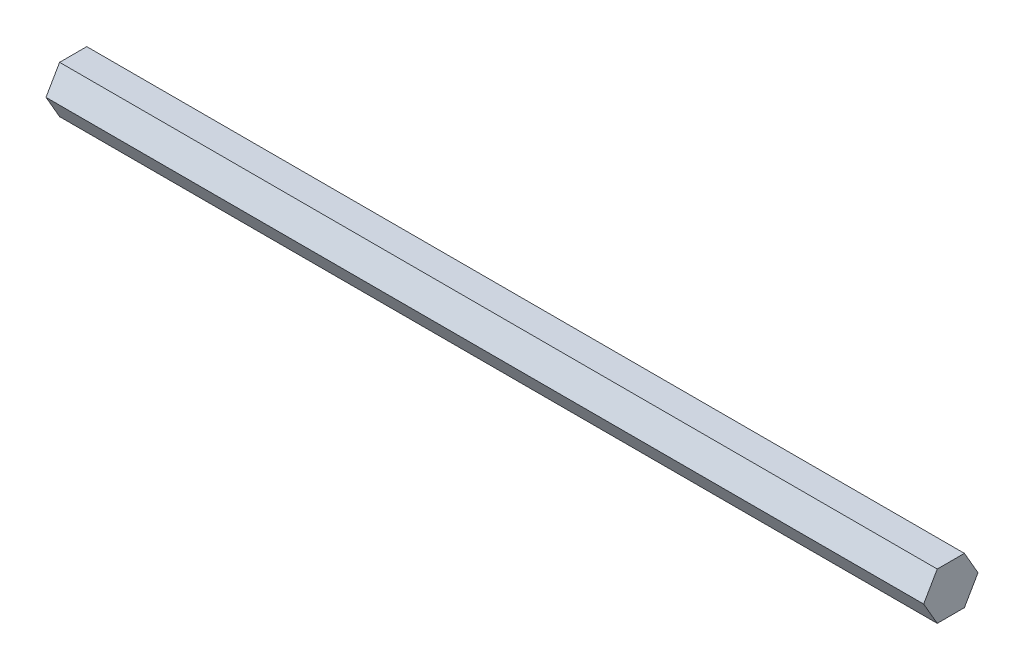
from build123d import *

# Parameters (mm, degrees)
BOSS_EXTRUDE1_DEPTH = 236.85


with BuildPart() as part:
    # Sketch1 → Boss-Extrude1 (new body)
    with BuildSketch(Plane(origin=(0, 0, 0), x_dir=(0, 0, -1), z_dir=(1, 0, 0))):
        Polygon((7.332348419, 0), (3.666174209, 6.35), (-3.666174209, 6.35), (-7.332348419, 0), (-3.666174209, -6.35), (3.666174209, -6.35), align=None)
    extrude(amount=BOSS_EXTRUDE1_DEPTH)


solid = part.part
